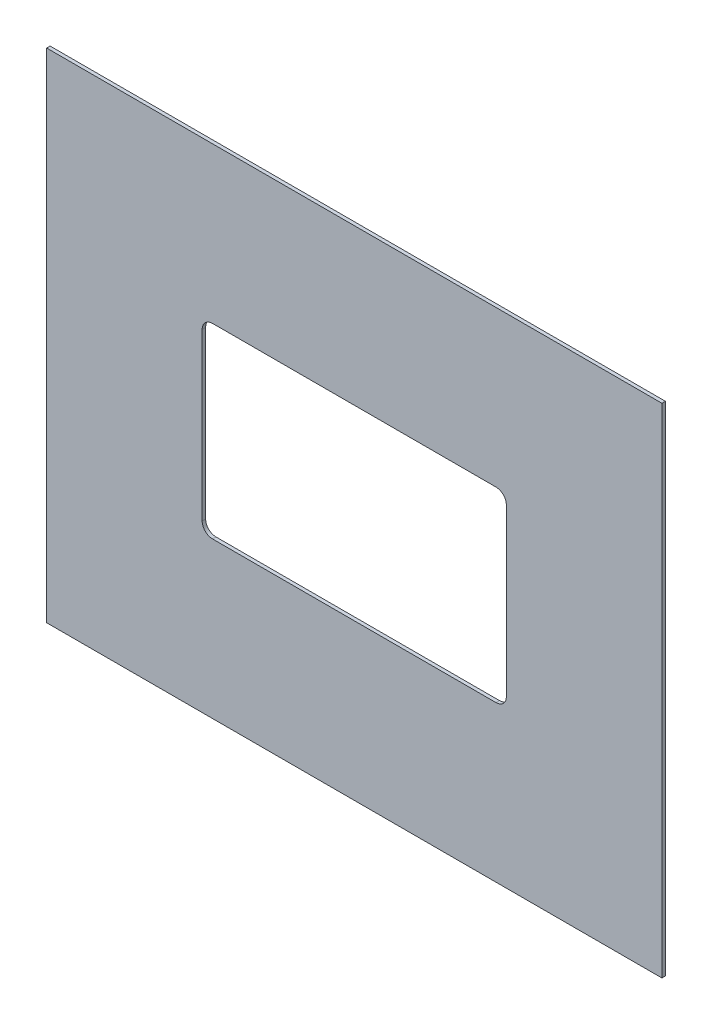
from build123d import *

# Parameters (mm, degrees)
SKETCH1_W           = 178
SKETCH1_H           = 144
BOSS_EXTRUDE1_DEPTH = 1


with BuildPart() as part:
    # Sketch1 → Boss-Extrude1 (new body)
    with BuildSketch(Plane.XY):
        with Locations((2.38778914, -10.649480895)):
            Rectangle(SKETCH1_W, SKETCH1_H)
        with BuildLine():
            Line((-38.61221086, 16.350519105), (43.38778914, 16.350519105))
            ThreePointArc((43.38778914, 16.350519105), (45.509109484, 15.471839449), (46.38778914, 13.350519105))
            Line((46.38778914, 13.350519105), (46.38778914, -34.649480895))
            ThreePointArc((46.38778914, -34.649480895), (45.509109484, -36.770801238), (43.38778914, -37.649480895))
            Line((43.38778914, -37.649480895), (-38.61221086, -37.649480895))
            ThreePointArc((-38.61221086, -37.649480895), (-40.733531203, -36.770801238), (-41.61221086, -34.649480895))
            Line((-41.61221086, -34.649480895), (-41.61221086, 13.350519105))
            ThreePointArc((-41.61221086, 13.350519105), (-40.733531203, 15.471839449), (-38.61221086, 16.350519105))
        make_face(mode=Mode.SUBTRACT)
    extrude(amount=BOSS_EXTRUDE1_DEPTH)


solid = part.part
